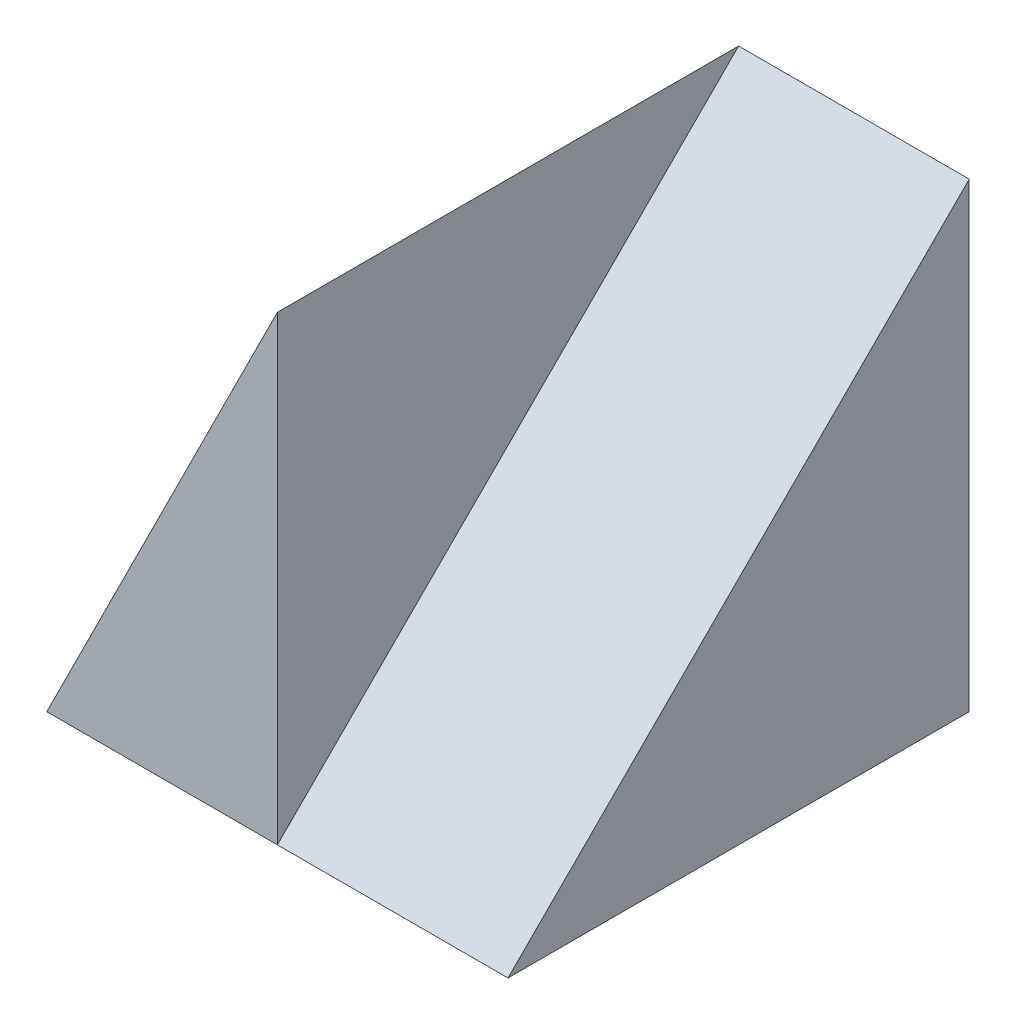
from build123d import *

# Parameters (mm, degrees)
SKETCH1_W           = 40
SKETCH1_H           = 40
BOSS_EXTRUDE1_DEPTH = 40
CUT_EXTRUDE1_DEPTH  = 40
CUT_EXTRUDE3_DEPTH  = 20


with BuildPart() as part:
    # Sketch1 → Boss-Extrude1 (new body)
    with BuildSketch(Plane.XY):
        with Locations((20, 20)):
            Rectangle(SKETCH1_W, SKETCH1_H)
    extrude(amount=BOSS_EXTRUDE1_DEPTH)

    # Sketch2 → Cut-Extrude1 (cut)
    with BuildSketch(Plane.XY.offset(40)):
        Polygon((0, 0), (20, 40), (0, 40), align=None)
    extrude(amount=-CUT_EXTRUDE1_DEPTH, mode=Mode.SUBTRACT)

    # Sketch3 → Cut-Extrude3 (cut)
    with BuildSketch(Plane(origin=(40, 0, 0), x_dir=(0, 0, -1), z_dir=(1, 0, 0))):
        Polygon((0, 40), (-40, 40), (-20, 20), align=None)
        Polygon((-20, 20), (-40, 40), (-40, 0), align=None)
    extrude(amount=-CUT_EXTRUDE3_DEPTH, mode=Mode.SUBTRACT)


solid = part.part
